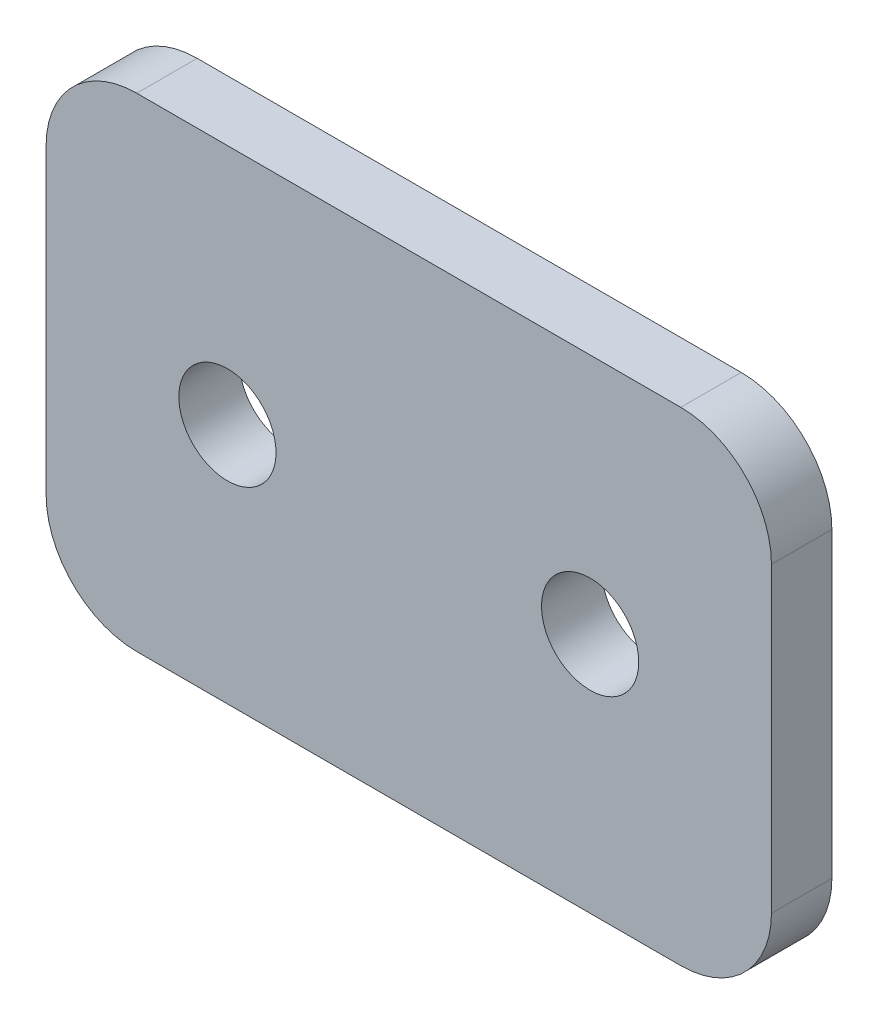
from build123d import *

# Parameters (mm, degrees)
SKETCH2_W           = 38.1
SKETCH2_H           = 25.4
SKETCH2_R           = 2.5527
BOSS_EXTRUDE1_DEPTH = 3.175
FILLET1_R           = 4.7625


with BuildPart() as part:
    # Sketch2 → Boss-Extrude1 (new body)
    with BuildSketch(Plane.XY):
        with Locations((19.05, 12.7)):
            Rectangle(SKETCH2_W, SKETCH2_H)
        with Locations((9.525, 12.7)):
            Circle(SKETCH2_R, mode=Mode.SUBTRACT)
        with Locations((28.575, 12.7)):
            Circle(SKETCH2_R, mode=Mode.SUBTRACT)
    extrude(amount=BOSS_EXTRUDE1_DEPTH)

    # Fillet1
    fillet1_edges = [part.edges().sort_by_distance(p)[0] for p in [
        (0, 25.4, 1.5875),
        (38.1, 25.4, 1.5875),
        (38.1, 0, 1.5875),
        (0, 0, 1.5875),
    ]]
    fillet(fillet1_edges, radius=FILLET1_R)


solid = part.part
